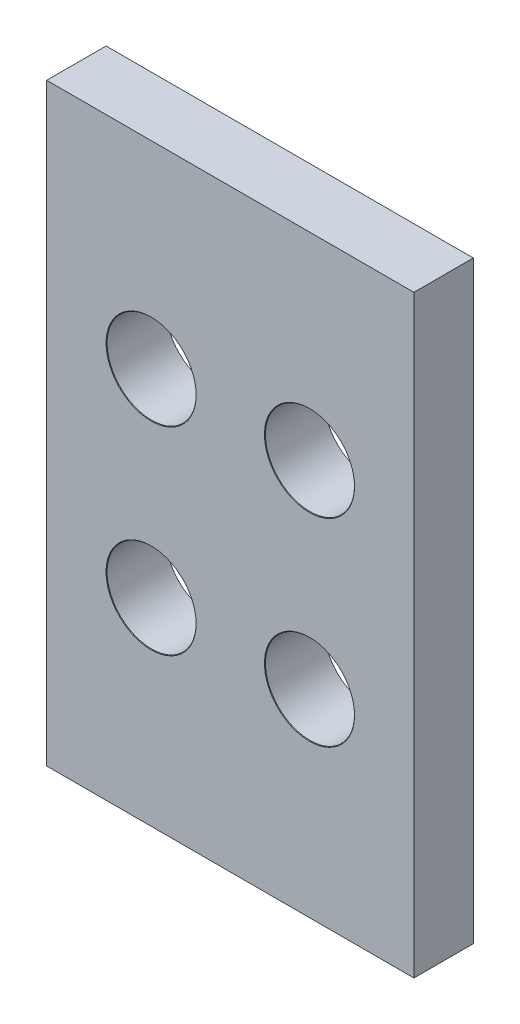
from build123d import *

# Parameters (mm, degrees)
SKETCH_1_W                   = 18.55
SKETCH_1_H                   = 30
EXTRUDE_1_DEPTH              = 1.5
HOLE_WIZARD_M4_1_D           = 4.5
HOLE_WIZARD_M4_1_DEPTH       = 3
HOLE_WIZARD_M4_1_CSINK_D     = 4.55
HOLE_WIZARD_M4_1_CSINK_ANGLE = 92


with BuildPart() as part:
    # 스케치1 → 보스-돌출1 (new body, symmetric)
    with BuildSketch(Plane.XY):
        Rectangle(SKETCH_1_W, SKETCH_1_H)
    extrude(amount=EXTRUDE_1_DEPTH, both=True)

    # M4 여유 구멍1
    with Locations(Plane.XY.offset(1.5)):
        with Locations((-4, -5.005), (4, 5.005), (-4, 5.005), (4, -5.005)):
            CounterSinkHole(HOLE_WIZARD_M4_1_D / 2, HOLE_WIZARD_M4_1_CSINK_D / 2, depth=HOLE_WIZARD_M4_1_DEPTH, counter_sink_angle=HOLE_WIZARD_M4_1_CSINK_ANGLE)


solid = part.part
